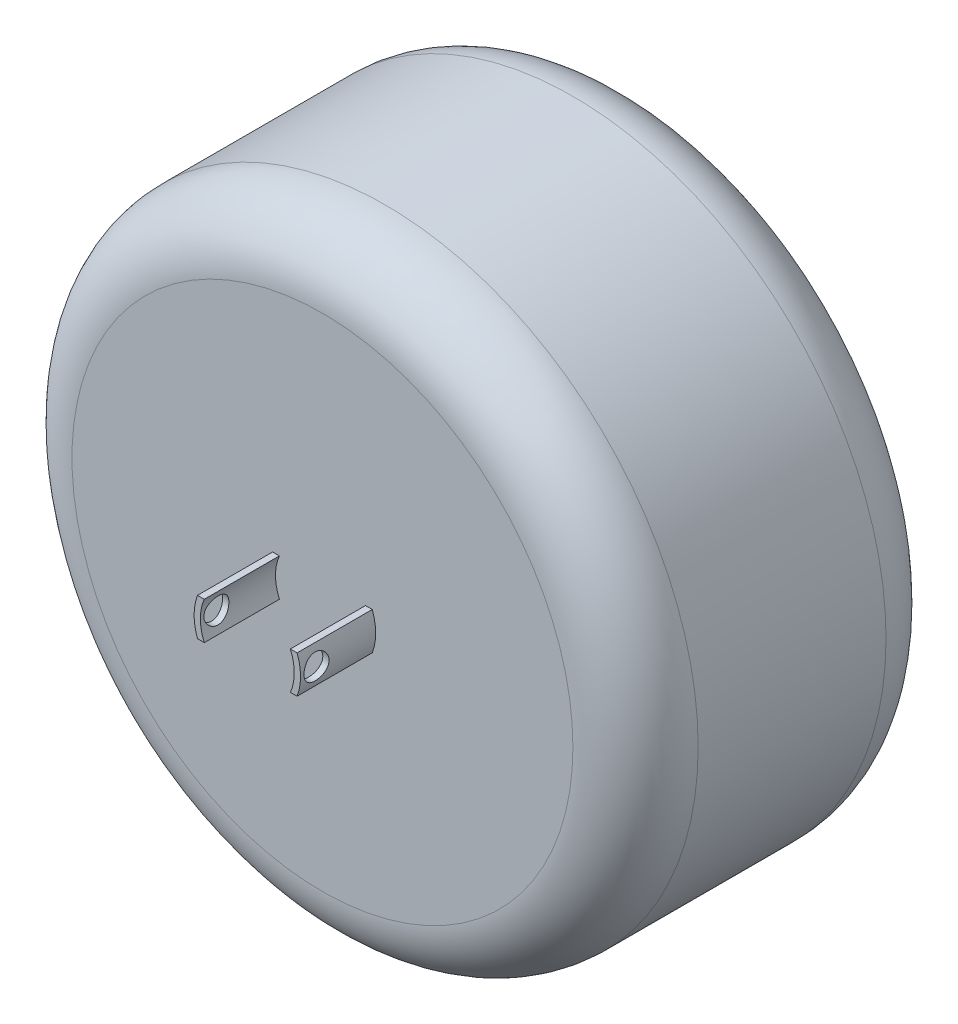
from build123d import *

# Parameters (mm, degrees)
SKETCH2_R                = 50
BOSS_EXTRUDE1_DEPTH      = 50
SKETCH3_R                = 13
BOSS_EXTRUDE2_DEPTH      = 12
SKETCH7_R                = 12
CUT_EXTRUDE3_DEPTH       = 12
SKETCH11_R               = 8.5
BOSS_EXTRUDE3_DEPTH      = 12
SKETCH12_R               = 7.5
CUT_EXTRUDE7_DEPTH       = 12
CUT_EXTRUDE8_DEPTH       = 12
CUT_EXTRUDE8_DEPTH_BACK  = 12
SKETCH15_R               = 2
CUT_EXTRUDE9_DEPTH       = 12
CUT_EXTRUDE9_DEPTH_BACK  = 12
SKETCH16_W               = 12
SKETCH16_H               = 5.5
CUT_EXTRUDE12_DEPTH      = 16
CUT_EXTRUDE12_DEPTH_BACK = 16
SKETCH19_R               = 2
CUT_EXTRUDE13_DEPTH      = 16
CUT_EXTRUDE13_DEPTH_BACK = 16
SKETCH20_W               = 10
SKETCH20_H               = 12
FILLET1_R                = 10


with BuildPart() as part:
    # Sketch2 → Boss-Extrude1 (new body)
    with BuildSketch(Plane.XY):
        Circle(SKETCH2_R)
    extrude(amount=BOSS_EXTRUDE1_DEPTH)

    # Sketch3 → Boss-Extrude2 (add)
    with BuildSketch(Plane(origin=(0, 0, 0), x_dir=(-1, 0, 0), z_dir=(0, 0, -1))):
        Circle(SKETCH3_R)
    extrude(amount=BOSS_EXTRUDE2_DEPTH)

    # Sketch7 → Cut-Extrude3 (cut)
    with BuildSketch(Plane(origin=(0, 0, -12), x_dir=(-1, 0, 0), z_dir=(0, 0, -1))):
        Circle(SKETCH7_R)
    extrude(amount=-CUT_EXTRUDE3_DEPTH, mode=Mode.SUBTRACT)

    # Sketch11 → Boss-Extrude3 (add)
    with BuildSketch(Plane.XY.offset(50)):
        Circle(SKETCH11_R)
    extrude(amount=BOSS_EXTRUDE3_DEPTH)

    # Sketch12 → Cut-Extrude7 (cut)
    with BuildSketch(Plane.XY.offset(62)):
        Circle(SKETCH12_R)
    extrude(amount=-CUT_EXTRUDE7_DEPTH, mode=Mode.SUBTRACT)

    # Sketch15 → Cut-Extrude8 (cut, two sides: drawn at the far end of the back side and taken through both)
    with BuildSketch(Plane(origin=(0, 0, 0), x_dir=(0, 0, -1), z_dir=(1, 0, 0)).offset(-CUT_EXTRUDE8_DEPTH_BACK)):
        with Locations((-59.444436812, 0)):
            Circle(SKETCH15_R)
    extrude(amount=CUT_EXTRUDE8_DEPTH + CUT_EXTRUDE8_DEPTH_BACK, mode=Mode.SUBTRACT)

    # Sketch16 → Cut-Extrude9 (cut, two sides: drawn at the far end of the back side and taken through both)
    with BuildSketch(Plane(origin=(0, 0, 0), x_dir=(0, 0, -1), z_dir=(1, 0, 0)).offset(-CUT_EXTRUDE9_DEPTH_BACK)):
        with Locations((-56, 5.75)):
            Rectangle(SKETCH16_W, SKETCH16_H)
        with Locations((-56, -5.75)):
            Rectangle(SKETCH16_W, SKETCH16_H)
    extrude(amount=CUT_EXTRUDE9_DEPTH + CUT_EXTRUDE9_DEPTH_BACK, mode=Mode.SUBTRACT)

    # Sketch19 → Cut-Extrude12 (cut, two sides: drawn at the far end of the back side and taken through both)
    with BuildSketch(Plane(origin=(0, 0, 0), x_dir=(1, 0, 0), z_dir=(0, 1, 0)).offset(-CUT_EXTRUDE12_DEPTH_BACK)):
        with Locations((0, 7.94)):
            Circle(SKETCH19_R)
    extrude(amount=CUT_EXTRUDE12_DEPTH + CUT_EXTRUDE12_DEPTH_BACK, mode=Mode.SUBTRACT)

    # Sketch20 → Cut-Extrude13 (cut, two sides: drawn at the far end of the back side and taken through both)
    with BuildSketch(Plane(origin=(0, 0, 0), x_dir=(1, 0, 0), z_dir=(0, 1, 0)).offset(-CUT_EXTRUDE13_DEPTH_BACK)):
        with Locations((-8, 6)):
            Rectangle(SKETCH20_W, SKETCH20_H)
        with Locations((8, 6)):
            Rectangle(SKETCH20_W, SKETCH20_H)
    extrude(amount=CUT_EXTRUDE13_DEPTH + CUT_EXTRUDE13_DEPTH_BACK, mode=Mode.SUBTRACT)

    # Fillet1
    fillet1_edges = [part.edges().sort_by_distance(p)[0] for p in [
        (-50, 0, 0),
        (-50, 0, 50),
    ]]
    fillet(fillet1_edges, radius=FILLET1_R)


solid = part.part
